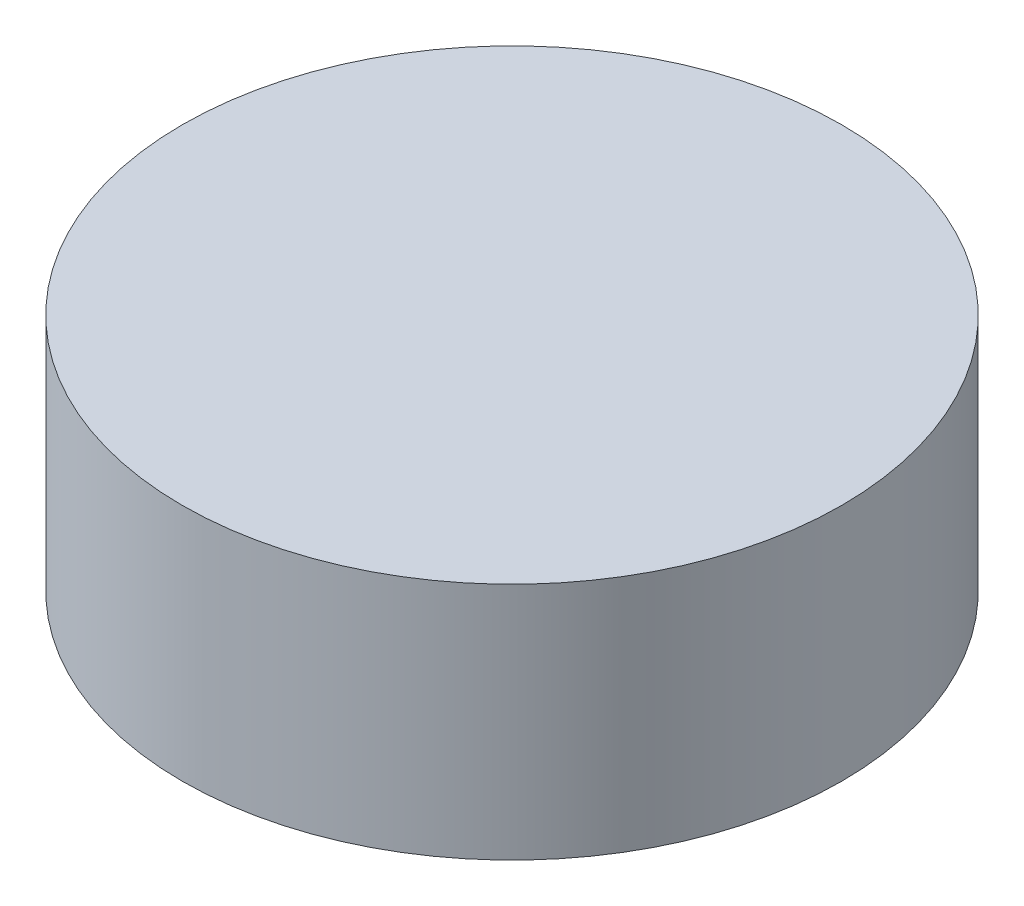
from build123d import *

# Parameters (mm, degrees)
SKETCH1_R           = 13.8
BOSS_EXTRUDE1_DEPTH = 10


with BuildPart() as part:
    # Sketch1 → Boss-Extrude1 (new body)
    with BuildSketch(Plane(origin=(0, 0, 0), x_dir=(1, 0, 0), z_dir=(0, 1, 0))):
        Circle(SKETCH1_R)
    extrude(amount=BOSS_EXTRUDE1_DEPTH)


solid = part.part
